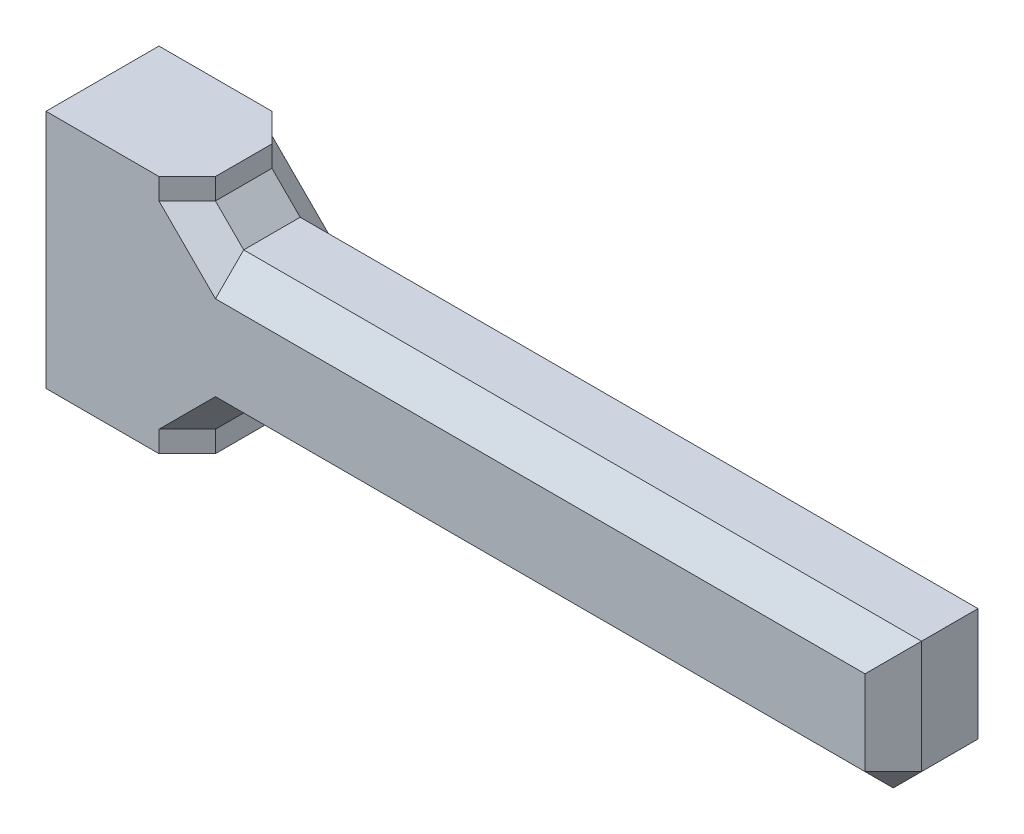
from build123d import *

# Parameters (mm, degrees)
BASE_DEPTH         = 4
CHAMFER1_SIZE      = 1
SKETCH2_R          = 1.5
CUT_EXTRUDE1_DEPTH = 2.5


with BuildPart() as part:
    # Sketch1 → BASE (new body)
    with BuildSketch(Plane.XY):
        Polygon((0, -4.25), (0, -2.5), (25, -2.5), (25, 2.5), (0, 2.5), (0, 4.25), (-5, 4.25), (-5, -4.25), align=None)
    extrude(amount=BASE_DEPTH)

    # Chamfer1
    chamfer1_edges = [part.edges().sort_by_distance(p)[0] for p in [
        (0, -3.375, 0),
        (12.5, -2.5, 0),
        (25, 0, 0),
        (0, -3.375, 4),
        (0, 2.5, 2),
        (0, -2.5, 2),
        (25, -2.5, 2),
        (0, 3.375, 4),
        (12.5, 2.5, 4),
        (25, 0, 4),
        (12.5, 2.5, 0),
        (12.5, -2.5, 4),
        (0, 3.375, 0),
    ]]
    chamfer(chamfer1_edges, length=CHAMFER1_SIZE)

    # Sketch2 → Cut-Extrude1 (cut)
    with BuildSketch(Plane.ZY.offset(5)):
        with Locations((2.025680481, 0.035876769)):
            Circle(SKETCH2_R)
    extrude(amount=-CUT_EXTRUDE1_DEPTH, mode=Mode.SUBTRACT)


solid = part.part
